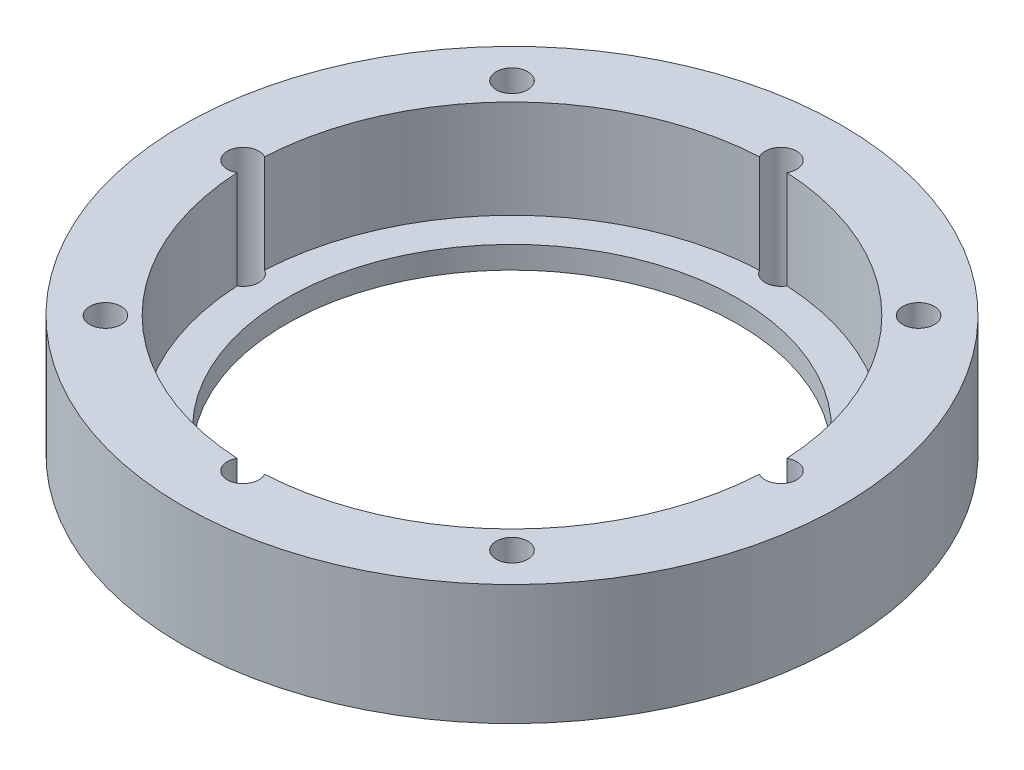
from build123d import *

# Parameters (mm, degrees)
SKETCH2_R          = 1.125
CUT_EXTRUDE1_DEPTH = 35.325575833
SKETCH3_R          = 1.125
CUT_EXTRUDE2_DEPTH = 35.325575833
CIRPATTERN1_COUNT  = 4


with BuildPart() as part:
    # Sketch1 → Revolve1 (revolve)
    with BuildSketch(Plane.XY):
        Polygon((-23.5, 8.5875), (-18.65, 8.5875), (-18.65, 1.5875), (-16.11, 1.5875), (-16.11, 0), (-23.5, 0), align=None)
    revolve(axis=Axis((0, 0, 0), (0, 1, 0)))

    # Sketch2 → Cut-Extrude1 (cut, through all)
    with BuildSketch(Plane(origin=(0, 0, 0), x_dir=(-1, 0, 0), z_dir=(0, -1, 0))):
        with Locations((19.177, 0)):
            Circle(SKETCH2_R)
    cut_extrude1 = extrude(amount=-CUT_EXTRUDE1_DEPTH, mode=Mode.SUBTRACT)

    # Sketch3 → Cut-Extrude2 (cut, through all)
    with BuildSketch(Plane.XZ):
        with Locations((-14.495689029, 14.495689029)):
            Circle(SKETCH3_R)
    cut_extrude2 = extrude(amount=-CUT_EXTRUDE2_DEPTH, mode=Mode.SUBTRACT)

    # CirPattern1: Cut-Extrude1, Cut-Extrude2 ×4 about axis
    cirpattern1_axis = Axis((0, 8.5875, 0), (0, -1, 0))
    add([cut_extrude1.rotate(cirpattern1_axis, i * 360 / CIRPATTERN1_COUNT) for i in range(1, CIRPATTERN1_COUNT)], mode=Mode.SUBTRACT)
    add([cut_extrude2.rotate(cirpattern1_axis, i * 360 / CIRPATTERN1_COUNT) for i in range(1, CIRPATTERN1_COUNT)], mode=Mode.SUBTRACT)


solid = part.part
